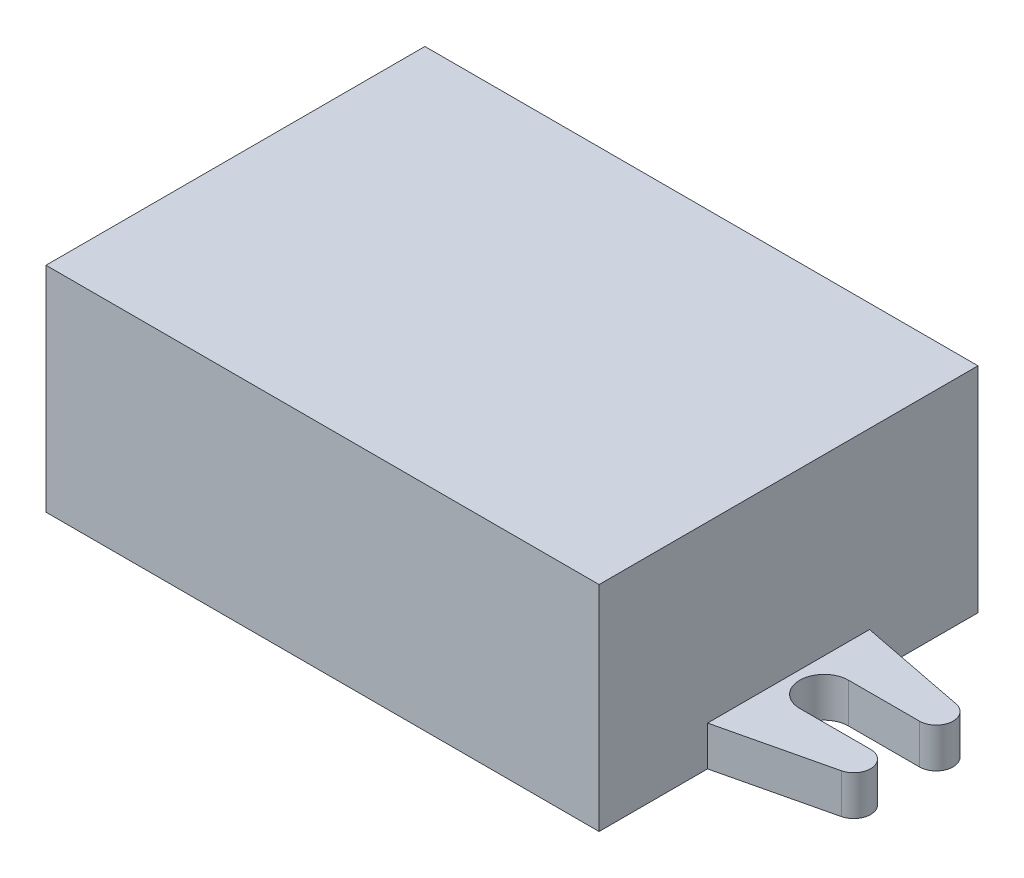
from build123d import *

# Parameters (mm, degrees)
SKETCH1_W           = 45.974
SKETCH1_H           = 31.496
BOSS_EXTRUDE2_DEPTH = 17.78
BOSS_EXTRUDE6_DEPTH = 3.302


with BuildPart() as part:
    # Sketch1 → Boss-Extrude2 (new body)
    with BuildSketch(Plane(origin=(0, 0, 0), x_dir=(1, 0, 0), z_dir=(0, 1, 0))):
        with Locations((1.215537396, -0.182473566)):
            Rectangle(SKETCH1_W, SKETCH1_H)
    extrude(amount=BOSS_EXTRUDE2_DEPTH)

    # Sketch2 → Boss-Extrude6 (add)
    with BuildSketch(Plane.XZ):
        with BuildLine():
            Line((-21.771462604, 6.913473566), (-21.771462604, -6.548526434))
            Line((-21.771462604, -6.548526434), (-30.800796473, -4.778472942))
            ThreePointArc((-30.800796473, -4.778472942), (-31.824571926, -3.246797777), (-30.439504653, -2.032))
            Line((-30.439504653, -2.032), (-24.546579859, -2.032))
            ThreePointArc((-24.546579859, -2.032), (-22.514579859, 0), (-24.546579859, 2.032))
            Line((-24.546579859, 2.032), (-30.439504653, 2.032))
            ThreePointArc((-30.439504653, 2.032), (-31.827108275, 3.267243429), (-30.76084181, 4.78854089))
            Line((-30.76084181, 4.78854089), (-21.771462604, 6.913473566))
        make_face()
        with BuildLine():
            Line((32.870579445, 2.032), (26.977654651, 2.032))
            ThreePointArc((26.977654651, 2.032), (24.945654651, 0), (26.977654651, -2.032))
            Line((26.977654651, -2.032), (32.870579445, -2.032))
            ThreePointArc((32.870579445, -2.032), (34.255646718, -3.246797777), (33.231871264, -4.778472942))
            Line((33.231871264, -4.778472942), (24.202537396, -6.548526434))
            Line((24.202537396, -6.548526434), (24.202537396, 6.913473566))
            Line((24.202537396, 6.913473566), (33.191916602, 4.78854089))
            ThreePointArc((33.191916602, 4.78854089), (34.258183067, 3.267243429), (32.870579445, 2.032))
        make_face()
    extrude(amount=-BOSS_EXTRUDE6_DEPTH)


solid = part.part
